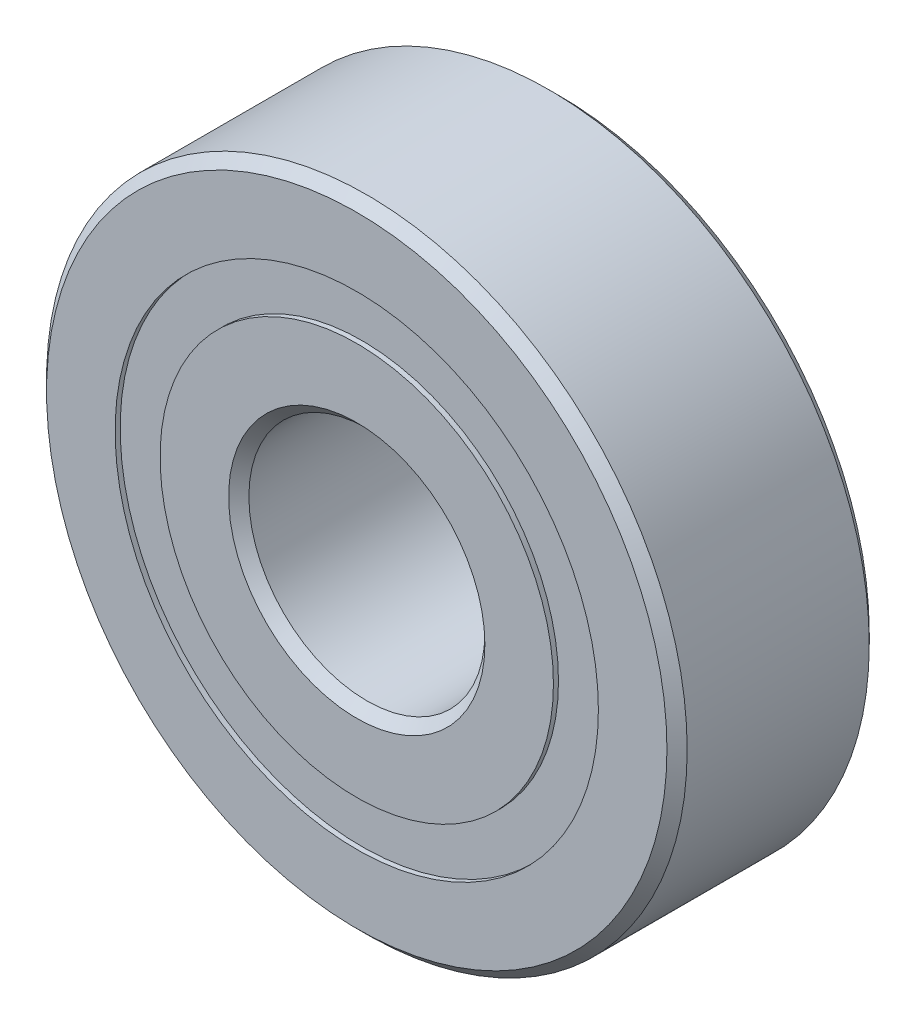
from build123d import *

# Parameters (mm, degrees)
CIRPATTERN1_COUNT = 13
SKETCH5_W         = 1.359288015
SKETCH5_H         = 1.333333334


with BuildPart() as part:
    # Sketch1 → Revolve1 (revolve)
    with BuildSketch(Plane(origin=(0, 0, 0), x_dir=(0, 0, -1), z_dir=(1, 0, 0))):
        with BuildLine():
            Line((2.7, 9.5), (-2.7, 9.5))
            Line((-2.7, 9.5), (-3, 9.2))
            Line((-3, 9.2), (-3, 7.166666667))
            Line((-3, 7.166666667), (-1.333333333, 7.166666667))
            ThreePointArc((-1.333333333, 7.166666667), (0, 7.990711985), (1.333333333, 7.166666667))
            Line((1.333333333, 7.166666667), (3, 7.166666667))
            Line((3, 7.166666667), (3, 9.2))
            Line((3, 9.2), (2.7, 9.5))
        make_face()
    revolve(axis=Axis((0, 0, 3), (0, 0, -1)))


with BuildPart() as body_2:
    # Sketch2 → Revolve2 (revolve)
    with BuildSketch(Plane(origin=(0, 0, 0), x_dir=(0, 0, -1), z_dir=(1, 0, 0))):
        with BuildLine():
            Line((-3, 5.833333333), (-1.333333333, 5.833333333))
            ThreePointArc((-1.333333333, 5.833333333), (0, 5.009288015), (1.333333333, 5.833333333))
            Line((1.333333333, 5.833333333), (3, 5.833333333))
            Line((3, 5.833333333), (3, 3.8))
            Line((3, 3.8), (2.7, 3.5))
            Line((2.7, 3.5), (-2.7, 3.5))
            Line((-2.7, 3.5), (-3, 3.8))
            Line((-3, 3.8), (-3, 5.833333333))
        make_face()
    revolve(axis=Axis((0, 0, 3), (0, 0, -1)))


with BuildPart() as body_3:
    # Sketch3 → Revolve3 (revolve)
    with BuildSketch(Plane(origin=(0, 0, 0), x_dir=(0, 0, -1), z_dir=(1, 0, 0))):
        with BuildLine():
            Line((-1.490711985, 6.5), (1.490711985, 6.5))
            ThreePointArc((1.490711985, 6.5), (0, 7.990711985), (-1.490711985, 6.5))
        make_face()
    revolve(axis=Axis((0, 6.5, 1.490711985), (0, 0, -1)))


with BuildPart() as cirpattern1_1:
    # CirPattern1: pattern copy
    add(body_3.part.rotate(Axis((0, 0, -3), (0, 0, 1)), 1 * 360 / CIRPATTERN1_COUNT))


with BuildPart() as cirpattern1_2:
    # CirPattern1: pattern copy
    add(body_3.part.rotate(Axis((0, 0, -3), (0, 0, 1)), 2 * 360 / CIRPATTERN1_COUNT))


with BuildPart() as cirpattern1_3:
    # CirPattern1: pattern copy
    add(body_3.part.rotate(Axis((0, 0, -3), (0, 0, 1)), 3 * 360 / CIRPATTERN1_COUNT))


with BuildPart() as cirpattern1_4:
    # CirPattern1: pattern copy
    add(body_3.part.rotate(Axis((0, 0, -3), (0, 0, 1)), 4 * 360 / CIRPATTERN1_COUNT))


with BuildPart() as cirpattern1_5:
    # CirPattern1: pattern copy
    add(body_3.part.rotate(Axis((0, 0, -3), (0, 0, 1)), 5 * 360 / CIRPATTERN1_COUNT))


with BuildPart() as cirpattern1_6:
    # CirPattern1: pattern copy
    add(body_3.part.rotate(Axis((0, 0, -3), (0, 0, 1)), 6 * 360 / CIRPATTERN1_COUNT))


with BuildPart() as cirpattern1_7:
    # CirPattern1: pattern copy
    add(body_3.part.rotate(Axis((0, 0, -3), (0, 0, 1)), 7 * 360 / CIRPATTERN1_COUNT))


with BuildPart() as cirpattern1_8:
    # CirPattern1: pattern copy
    add(body_3.part.rotate(Axis((0, 0, -3), (0, 0, 1)), 8 * 360 / CIRPATTERN1_COUNT))


with BuildPart() as cirpattern1_9:
    # CirPattern1: pattern copy
    add(body_3.part.rotate(Axis((0, 0, -3), (0, 0, 1)), 9 * 360 / CIRPATTERN1_COUNT))


with BuildPart() as cirpattern1_10:
    # CirPattern1: pattern copy
    add(body_3.part.rotate(Axis((0, 0, -3), (0, 0, 1)), 10 * 360 / CIRPATTERN1_COUNT))


with BuildPart() as cirpattern1_11:
    # CirPattern1: pattern copy
    add(body_3.part.rotate(Axis((0, 0, -3), (0, 0, 1)), 11 * 360 / CIRPATTERN1_COUNT))


with BuildPart() as cirpattern1_12:
    # CirPattern1: pattern copy
    add(body_3.part.rotate(Axis((0, 0, -3), (0, 0, 1)), 12 * 360 / CIRPATTERN1_COUNT))


with BuildPart() as body_16:
    # Sketch5 → Revolve5 (revolve)
    with BuildSketch(Plane(origin=(0, 0, 0), x_dir=(0, 0, -1), z_dir=(1, 0, 0))):
        with Locations((-2.170355993, 6.5)):
            Rectangle(SKETCH5_W, SKETCH5_H)
        with Locations((2.170355993, 6.5)):
            Rectangle(SKETCH5_W, SKETCH5_H)
    revolve(axis=Axis((0, 0, 3), (0, 0, -1)))


solid = Compound([part.part, body_2.part, body_3.part, cirpattern1_1.part, cirpattern1_2.part, cirpattern1_3.part, cirpattern1_4.part, cirpattern1_5.part, cirpattern1_6.part, cirpattern1_7.part, cirpattern1_8.part, cirpattern1_9.part, cirpattern1_10.part, cirpattern1_11.part, cirpattern1_12.part, body_16.part])
